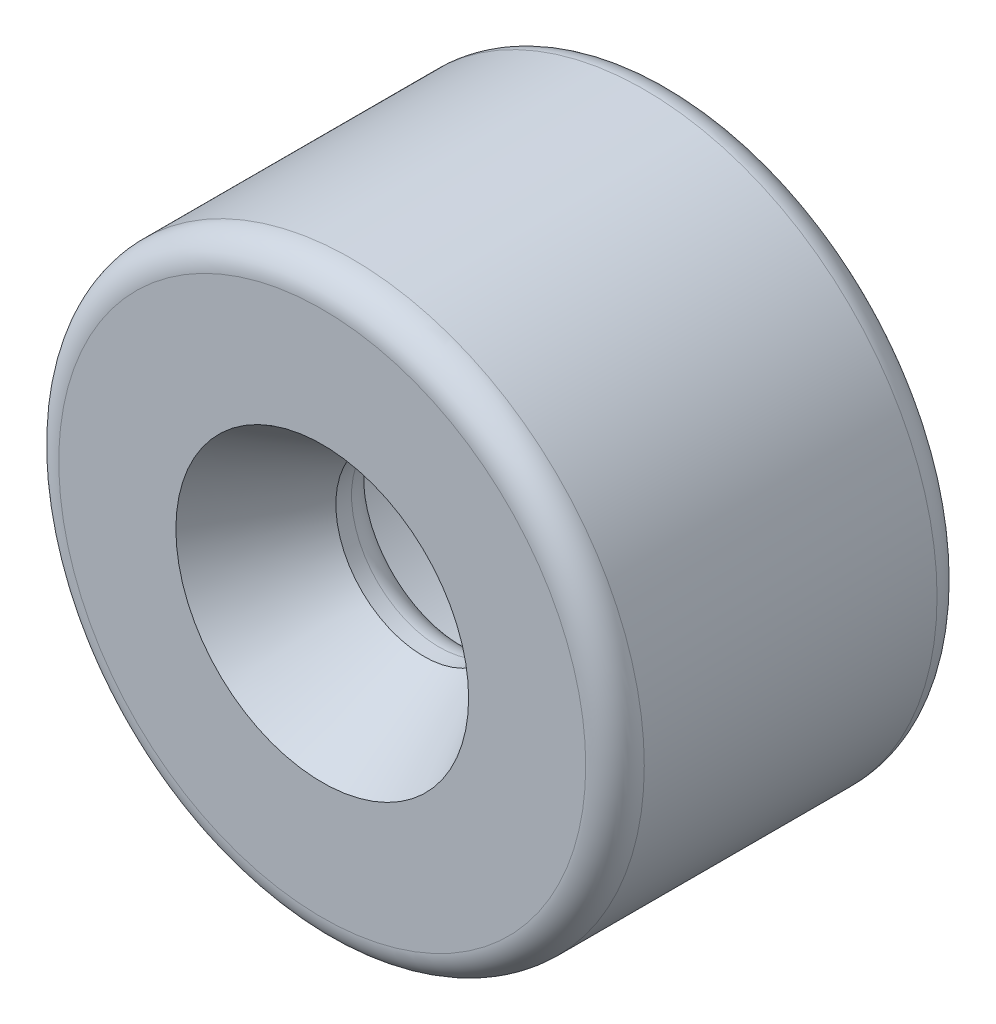
from build123d import *

# Parameters (mm, degrees)
SKETCH1_R           = 5
SKETCH1_R_2         = 1.5
BOSS_EXTRUDE1_DEPTH = 6
SKETCH2_R           = 3.75
CUT_EXTRUDE1_DEPTH  = 3.5
FILLET1_R           = 0.5
CHAMFER1_SIZE       = 1
CHAMFER1_SIZE2      = 1.732050808


with BuildPart() as part:
    # Sketch1 → Boss-Extrude1 (new body)
    with BuildSketch(Plane.XY):
        Circle(SKETCH1_R)
        Circle(SKETCH1_R_2, mode=Mode.SUBTRACT)
    extrude(amount=BOSS_EXTRUDE1_DEPTH)

    # Sketch2 → Cut-Extrude1 (cut)
    with BuildSketch(Plane.XY):
        Circle(SKETCH2_R)
    extrude(amount=CUT_EXTRUDE1_DEPTH, mode=Mode.SUBTRACT)

    # Fillet1
    fillet1_edges = [part.edges().sort_by_distance(p)[0] for p in [
        (-1.5, 0, 3.5),
        (-3.75, 0, 0),
        (-5, 0, 0),
        (-5, 0, 6),
    ]]
    fillet(fillet1_edges, radius=FILLET1_R)

    # Chamfer1
    chamfer1_edges = [part.edges().sort_by_distance(p)[0] for p in [
        (-1.5, 0, 6),
    ]]
    chamfer1_side = [part.faces().sort_by_distance(p)[0] for p in [
        (-4.372720779, 0, 6),
    ]]
    chamfer(chamfer1_edges, length=CHAMFER1_SIZE, length2=CHAMFER1_SIZE2, reference=chamfer1_side[0])


solid = part.part
